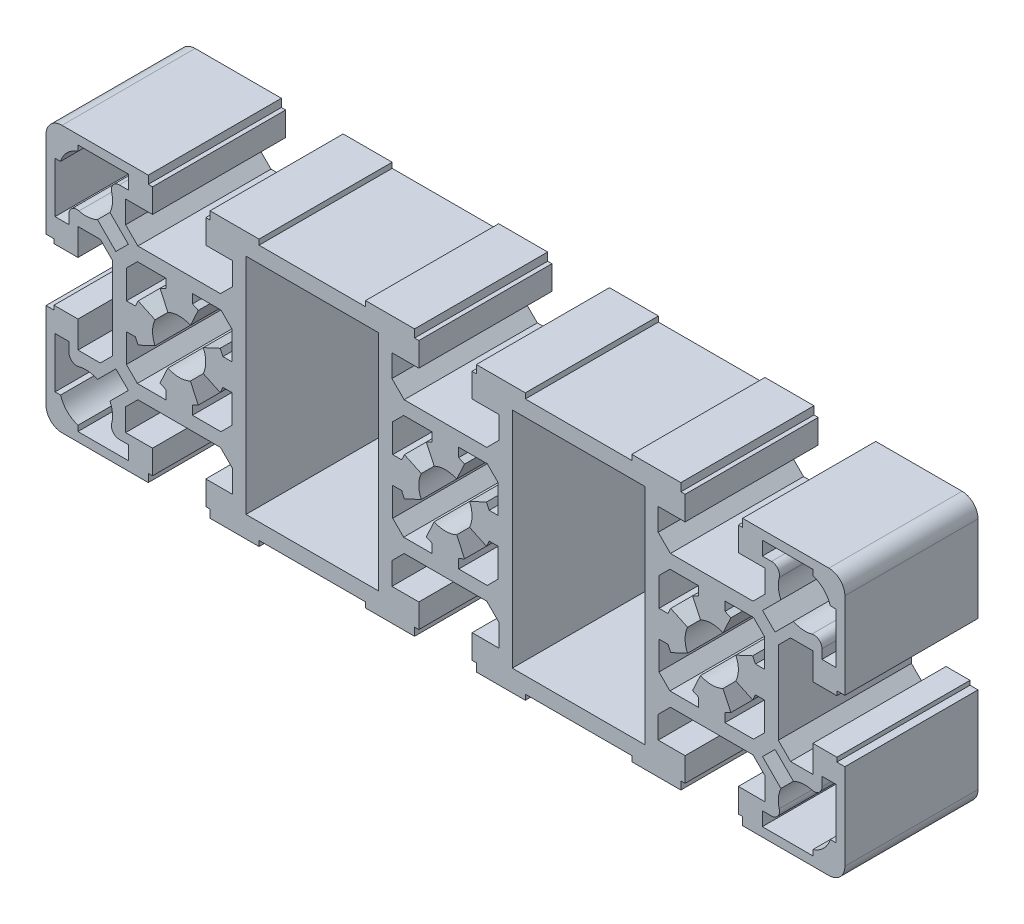
from build123d import *

# Parameters (mm, degrees)
SKETCH1_W           = 24.9
SKETCH1_H           = 41.99999997
BOSS_EXTRUDE1_DEPTH = 25


with BuildPart() as part:
    # Sketch1 → Boss-Extrude1 (new body)
    with BuildSketch(Plane.XY):
        with BuildLine():
            Line((73.500000293, 4.999999371), (73.500000293, 5.799999386))
            Line((73.500000293, 5.799999386), (75.000000293, 5.799999386))
            Line((75.000000293, 5.799999386), (75.000000293, 21.999999371))
            ThreePointArc((75.000000293, 21.999999371), (74.121320637, 24.121319714), (72.000000293, 24.999999371))
            Line((72.000000293, 24.999999371), (55.800000293, 24.999999371))
            Line((55.800000293, 24.999999371), (55.800000293, 23.499999371))
            Line((55.800000293, 23.499999371), (55.000000293, 23.499999371))
            Line((55.000000293, 23.499999371), (55.000000293, 18.999999317))
            Line((55.000000293, 18.999999317), (60.050000326, 18.999999317))
            Line((60.050000326, 18.999999317), (60.050000326, 14.799999386))
            Line((60.050000326, 14.799999386), (57.750000311, 12.499999371))
            Line((57.750000311, 12.499999371), (42.250000311, 12.499999371))
            Line((42.250000311, 12.499999371), (39.950000311, 14.799999371))
            Line((39.950000311, 14.799999371), (39.950000311, 18.999999317))
            Line((39.950000311, 18.999999317), (45.000000293, 18.999999317))
            Line((45.000000293, 18.999999317), (45.000000293, 23.499999371))
            Line((45.000000293, 23.499999371), (44.200000293, 23.499999371))
            Line((44.200000293, 23.499999371), (44.200000293, 24.999999371))
            Line((44.200000293, 24.999999371), (35.000000293, 24.999999371))
            Line((35.000000293, 24.999999371), (35.000000293, 23.999999401))
            Line((35.000000293, 23.999999401), (15.000000358, 23.999999401))
            Line((15.000000358, 23.999999401), (15.000000358, 24.999999371))
            Line((15.000000358, 24.999999371), (5.800000358, 24.999999371))
            Line((5.800000358, 24.999999371), (5.800000358, 23.499999371))
            Line((5.800000358, 23.499999371), (5.000000293, 23.499999371))
            Line((5.000000293, 23.499999371), (5.000000293, 18.999999317))
            Line((5.000000293, 18.999999317), (10.05000031, 18.999999317))
            Line((10.05000031, 18.999999317), (10.05000031, 14.799999402))
            Line((10.05000031, 14.799999402), (7.750000278, 12.499999371))
            Line((7.750000278, 12.499999371), (-7.749999689, 12.499999371))
            Line((-7.749999689, 12.499999371), (-10.04999969, 14.799999372))
            Line((-10.04999969, 14.799999372), (-10.04999969, 18.999999317))
            Line((-10.04999969, 18.999999317), (-4.999999707, 18.999999317))
            Line((-4.999999707, 18.999999317), (-4.999999707, 23.499999371))
            Line((-4.999999707, 23.499999371), (-5.799999707, 23.499999371))
            Line((-5.799999707, 23.499999371), (-5.799999707, 24.999999371))
            Line((-5.799999707, 24.999999371), (-14.999999707, 24.999999371))
            Line((-14.999999707, 24.999999371), (-14.999999707, 23.999999401))
            Line((-14.999999707, 23.999999401), (-34.999999707, 23.999999401))
            Line((-34.999999707, 23.999999401), (-34.999999707, 24.999999371))
            Line((-34.999999707, 24.999999371), (-44.199999707, 24.999999371))
            Line((-44.199999707, 24.999999371), (-44.199999707, 23.499999371))
            Line((-44.199999707, 23.499999371), (-44.999999707, 23.499999371))
            Line((-44.999999707, 23.499999371), (-44.999999707, 18.999999317))
            Line((-44.999999707, 18.999999317), (-39.949999674, 18.999999317))
            Line((-39.949999674, 18.999999317), (-39.949999674, 14.799999386))
            Line((-39.949999674, 14.799999386), (-42.249999689, 12.499999371))
            Line((-42.249999689, 12.499999371), (-57.749999689, 12.499999371))
            Line((-57.749999689, 12.499999371), (-60.049999674, 14.799999356))
            Line((-60.049999674, 14.799999356), (-60.049999674, 18.999999317))
            Line((-60.049999674, 18.999999317), (-54.999999707, 18.999999317))
            Line((-54.999999707, 18.999999317), (-54.999999707, 23.499999371))
            Line((-54.999999707, 23.499999371), (-55.799999707, 23.499999371))
            Line((-55.799999707, 23.499999371), (-55.799999707, 24.999999371))
            Line((-55.799999707, 24.999999371), (-71.999999707, 24.999999371))
            ThreePointArc((-71.999999707, 24.999999371), (-74.12132005, 24.121319714), (-74.999999707, 21.999999371))
            Line((-74.999999707, 21.999999371), (-74.999999707, 5.799999386))
            Line((-74.999999707, 5.799999386), (-73.499999707, 5.799999386))
            Line((-73.499999707, 5.799999386), (-73.499999707, 4.999999371))
            Line((-73.499999707, 4.999999371), (-68.9999997, 4.999999371))
            Line((-68.9999997, 4.999999371), (-68.9999997, 10.049999386))
            Line((-68.9999997, 10.049999386), (-64.799999674, 10.049999386))
            Line((-64.799999674, 10.049999386), (-62.499999674, 7.749999386))
            Line((-62.499999674, 7.749999386), (-62.499999674, -7.750000614))
            Line((-62.499999674, -7.750000614), (-64.799999689, -10.050000629))
            Line((-64.799999689, -10.050000629), (-68.9999997, -10.050000629))
            Line((-68.9999997, -10.050000629), (-68.9999997, -5.000000629))
            Line((-68.9999997, -5.000000629), (-73.499999707, -5.000000629))
            Line((-73.499999707, -5.000000629), (-73.499999707, -5.800000614))
            Line((-73.499999707, -5.800000614), (-74.999999707, -5.800000614))
            Line((-74.999999707, -5.800000614), (-74.999999707, -22.000000629))
            ThreePointArc((-74.999999707, -22.000000629), (-74.12132005, -24.121320973), (-71.999999707, -25.000000629))
            Line((-71.999999707, -25.000000629), (-55.799999707, -25.000000629))
            Line((-55.799999707, -25.000000629), (-55.799999707, -23.500000629))
            Line((-55.799999707, -23.500000629), (-54.999999707, -23.500000629))
            Line((-54.999999707, -23.500000629), (-54.999999707, -19.000000636))
            Line((-54.999999707, -19.000000636), (-60.049999674, -19.000000636))
            Line((-60.049999674, -19.000000636), (-60.049999674, -14.800000614))
            Line((-60.049999674, -14.800000614), (-57.749999674, -12.500000614))
            Line((-57.749999674, -12.500000614), (-42.249999674, -12.500000614))
            Line((-42.249999674, -12.500000614), (-39.949999674, -14.800000614))
            Line((-39.949999674, -14.800000614), (-39.949999674, -19.000000636))
            Line((-39.949999674, -19.000000636), (-44.999999707, -19.000000636))
            Line((-44.999999707, -19.000000636), (-44.999999707, -23.500000629))
            Line((-44.999999707, -23.500000629), (-44.199999707, -23.500000629))
            Line((-44.199999707, -23.500000629), (-44.199999707, -25.000000629))
            Line((-44.199999707, -25.000000629), (-34.999999707, -25.000000629))
            Line((-34.999999707, -25.000000629), (-34.999999707, -24.000000599))
            Line((-34.999999707, -24.000000599), (-14.999999707, -24.000000599))
            Line((-14.999999707, -24.000000599), (-14.999999707, -25.000000629))
            Line((-14.999999707, -25.000000629), (-5.799999707, -25.000000629))
            Line((-5.799999707, -25.000000629), (-5.799999707, -23.500000629))
            Line((-5.799999707, -23.500000629), (-4.999999707, -23.500000629))
            Line((-4.999999707, -23.500000629), (-4.999999707, -19.000000636))
            Line((-4.999999707, -19.000000636), (-10.04999969, -19.000000636))
            Line((-10.04999969, -19.000000636), (-10.04999969, -14.80000063))
            Line((-10.04999969, -14.80000063), (-7.749999674, -12.500000614))
            Line((-7.749999674, -12.500000614), (7.750000326, -12.500000614))
            Line((7.750000326, -12.500000614), (10.05000031, -14.800000598))
            Line((10.05000031, -14.800000598), (10.05000031, -19.000000636))
            Line((10.05000031, -19.000000636), (5.000000293, -19.000000636))
            Line((5.000000293, -19.000000636), (5.000000293, -23.500000629))
            Line((5.000000293, -23.500000629), (5.800000358, -23.500000629))
            Line((5.800000358, -23.500000629), (5.800000358, -25.000000629))
            Line((5.800000358, -25.000000629), (15.000000358, -25.000000629))
            Line((15.000000358, -25.000000629), (15.000000358, -24.000000599))
            Line((15.000000358, -24.000000599), (35.000000293, -24.000000599))
            Line((35.000000293, -24.000000599), (35.000000293, -25.000000629))
            Line((35.000000293, -25.000000629), (44.200000293, -25.000000629))
            Line((44.200000293, -25.000000629), (44.200000293, -23.500000629))
            Line((44.200000293, -23.500000629), (45.000000293, -23.500000629))
            Line((45.000000293, -23.500000629), (45.000000293, -19.000000636))
            Line((45.000000293, -19.000000636), (39.950000311, -19.000000636))
            Line((39.950000311, -19.000000636), (39.950000311, -14.800000629))
            Line((39.950000311, -14.800000629), (42.250000326, -12.500000614))
            Line((42.250000326, -12.500000614), (57.750000326, -12.500000614))
            Line((57.750000326, -12.500000614), (60.050000326, -14.800000614))
            Line((60.050000326, -14.800000614), (60.050000326, -19.000000636))
            Line((60.050000326, -19.000000636), (55.000000293, -19.000000636))
            Line((55.000000293, -19.000000636), (55.000000293, -23.500000629))
            Line((55.000000293, -23.500000629), (55.800000293, -23.500000629))
            Line((55.800000293, -23.500000629), (55.800000293, -25.000000629))
            Line((55.800000293, -25.000000629), (72.000000293, -25.000000629))
            ThreePointArc((72.000000293, -25.000000629), (74.121320637, -24.121320973), (75.000000293, -22.000000629))
            Line((75.000000293, -22.000000629), (75.000000293, -5.800000614))
            Line((75.000000293, -5.800000614), (73.500000293, -5.800000614))
            Line((73.500000293, -5.800000614), (73.500000293, -5.000000629))
            Line((73.500000293, -5.000000629), (69.000000258, -5.000000629))
            Line((69.000000258, -5.000000629), (69.000000258, -10.050000629))
            Line((69.000000258, -10.050000629), (64.800000311, -10.050000629))
            Line((64.800000311, -10.050000629), (62.500000427, -7.750000745))
            Line((62.500000427, -7.750000745), (62.500000427, 7.749999487))
            Line((62.500000427, 7.749999487), (64.800000326, 10.049999386))
            Line((64.800000326, 10.049999386), (69.000000258, 10.049999386))
            Line((69.000000258, 10.049999386), (69.000000258, 4.999999371))
            Line((69.000000258, 4.999999371), (73.500000293, 4.999999371))
        make_face()
        with BuildLine():
            Line((72.269696311, 18.999999317), (73.300000192, 18.999999317))
            Line((73.300000192, 18.999999317), (73.300000192, 9.499999364))
            Line((73.300000192, 9.499999364), (70.70000022, 9.499999364))
            Line((70.70000022, 9.499999364), (70.70000022, 11.226244464))
            ThreePointArc((70.70000022, 11.226244464), (70.111465657, 12.417559181), (68.807692546, 12.674034051))
            ThreePointArc((68.807692546, 12.674034051), (67.044077418, 12.520829299), (65.337613319, 12.991775464))
            Line((65.337613319, 12.991775464), (61.884693162, 9.538855411))
            Line((61.884693162, 9.538855411), (59.538856304, 11.884692341))
            Line((59.538856304, 11.884692341), (62.991776426, 15.337612357))
            ThreePointArc((62.991776426, 15.337612357), (62.520830259, 17.04407647), (62.67403502, 18.80769161))
            ThreePointArc((62.67403502, 18.80769161), (62.417560154, 20.111464726), (61.226245435, 20.699999291))
            Line((61.226245435, 20.699999291), (59.500000371, 20.699999291))
            Line((59.500000371, 20.699999291), (59.500000371, 23.299999301))
            Line((59.500000371, 23.299999301), (69.000000258, 23.299999301))
            Line((69.000000258, 23.299999301), (69.000000258, 22.269695356))
            ThreePointArc((69.000000258, 22.269695356), (71.035534197, 21.03553325), (72.269696311, 18.999999317))
        make_face(mode=Mode.SUBTRACT)
        with BuildLine():
            Line((62.991776382, -15.337613665), (59.538856312, -11.884693596))
            Line((59.538856312, -11.884693596), (61.884693206, -9.538856703))
            Line((61.884693206, -9.538856703), (65.337613275, -12.991776772))
            ThreePointArc((65.337613275, -12.991776772), (67.044077392, -12.520830605), (68.807692536, -12.674035369))
            ThreePointArc((68.807692536, -12.674035369), (70.111465653, -12.417560504), (70.70000022, -11.226245784))
            Line((70.70000022, -11.226245784), (70.70000022, -9.500000636))
            Line((70.70000022, -9.500000636), (73.300000192, -9.500000636))
            Line((73.300000192, -9.500000636), (73.300000192, -19.000000636))
            Line((73.300000192, -19.000000636), (72.269696264, -19.000000636))
            ThreePointArc((72.269696264, -19.000000636), (71.035534165, -21.035534546), (69.000000258, -22.26969665))
            Line((69.000000258, -22.26969665), (69.000000258, -23.300000698))
            Line((69.000000258, -23.300000698), (59.500000371, -23.300000698))
            Line((59.500000371, -23.300000698), (59.500000371, -20.700000607))
            Line((59.500000371, -20.700000607), (61.226245393, -20.700000607))
            ThreePointArc((61.226245393, -20.700000607), (62.417560113, -20.111466041), (62.674034977, -18.807692924))
            ThreePointArc((62.674034977, -18.807692924), (62.520830215, -17.044077781), (62.991776382, -15.337613665))
        make_face(mode=Mode.SUBTRACT)
        with BuildLine():
            Line((-62.991775824, 15.337612346), (-59.538855738, 11.884692365))
            Line((-59.538855738, 11.884692365), (-61.884692596, 9.538855436))
            Line((-61.884692596, 9.538855436), (-65.337612718, 12.991775453))
            ThreePointArc((-65.337612718, 12.991775453), (-67.044076833, 12.520829286), (-68.807691976, 12.674034049))
            ThreePointArc((-68.807691976, 12.674034049), (-70.111465093, 12.417559184), (-70.699999659, 11.226244464))
            Line((-70.699999659, 11.226244464), (-70.699999659, 9.499999364))
            Line((-70.699999659, 9.499999364), (-73.299999743, 9.499999364))
            Line((-73.299999743, 9.499999364), (-73.299999743, 18.999999317))
            Line((-73.299999743, 18.999999317), (-72.269695706, 18.999999317))
            ThreePointArc((-72.269695706, 18.999999317), (-71.035533607, 21.035533227), (-68.9999997, 22.269695331))
            Line((-68.9999997, 22.269695331), (-68.9999997, 23.299999301))
            Line((-68.9999997, 23.299999301), (-59.4999997, 23.299999301))
            Line((-59.4999997, 23.299999301), (-59.4999997, 20.699999291))
            Line((-59.4999997, 20.699999291), (-61.226244836, 20.699999291))
            ThreePointArc((-61.226244836, 20.699999291), (-62.417559556, 20.111464725), (-62.674034421, 18.807691607))
            ThreePointArc((-62.674034421, 18.807691607), (-62.520829657, 17.044076463), (-62.991775824, 15.337612346))
        make_face(mode=Mode.SUBTRACT)
        with BuildLine():
            Line((-61.226244744, -20.700000607), (-59.4999997, -20.700000607))
            Line((-59.4999997, -20.700000607), (-59.4999997, -23.300000698))
            Line((-59.4999997, -23.300000698), (-68.9999997, -23.300000698))
            Line((-68.9999997, -23.300000698), (-68.9999997, -22.269696698))
            ThreePointArc((-68.9999997, -22.269696698), (-71.035533637, -21.035534576), (-72.269695754, -19.000000636))
            Line((-72.269695754, -19.000000636), (-73.299999743, -19.000000636))
            Line((-73.299999743, -19.000000636), (-73.299999743, -9.500000636))
            Line((-73.299999743, -9.500000636), (-70.699999659, -9.500000636))
            Line((-70.699999659, -9.500000636), (-70.699999659, -11.226245692))
            ThreePointArc((-70.699999659, -11.226245692), (-70.111465093, -12.417560412), (-68.807691975, -12.674035277))
            ThreePointArc((-68.807691975, -12.674035277), (-67.044076806, -12.520830511), (-65.337612664, -12.991776685))
            Line((-65.337612664, -12.991776685), (-61.884692647, -9.538856563))
            Line((-61.884692647, -9.538856563), (-59.538855684, -11.884693455))
            Line((-59.538855684, -11.884693455), (-62.991775737, -15.337613612))
            ThreePointArc((-62.991775737, -15.337613612), (-62.520829563, -17.044077754), (-62.674034329, -18.807692923))
            ThreePointArc((-62.674034329, -18.807692923), (-62.417559465, -20.111466041), (-61.226244744, -20.700000607))
        make_face(mode=Mode.SUBTRACT)
        with BuildLine():
            Line((-3.592255382, 7.703615177), (-2.113091613, 4.531538793))
            ThreePointArc((-2.113091613, 4.531538793), (-5.12e-07, 5), (2.113090685, 4.531539226))
            Line((2.113090685, 4.531539226), (3.592253985, 7.703616301))
            Line((3.592253985, 7.703616301), (2.500000278, 8.212942386))
            Line((2.500000278, 8.212942386), (2.500000278, 9.899999386))
            Line((2.500000278, 9.899999386), (7.846595278, 9.899999386))
            Line((7.846595278, 9.899999386), (9.900000262, 7.84659437))
            Line((9.900000262, 7.84659437), (9.900000262, 2.499999386))
            Line((9.900000262, 2.499999386), (8.212943262, 2.499999386))
            Line((8.212943262, 2.499999386), (7.703615719, 3.592255635))
            Line((7.703615719, 3.592255635), (4.531538793, 2.113091613))
            ThreePointArc((4.531538793, 2.113091613), (5, -2.7e-08), (4.531538771, -2.113091661))
            Line((4.531538771, -2.113091661), (7.70361614, -3.592255931))
            Line((7.70361614, -3.592255931), (8.212943262, -2.500000614))
            Line((8.212943262, -2.500000614), (9.900000262, -2.500000614))
            Line((9.900000262, -2.500000614), (9.900000262, -7.846595598))
            Line((9.900000262, -7.846595598), (7.846595278, -9.900000614))
            Line((7.846595278, -9.900000614), (2.500000278, -9.900000614))
            Line((2.500000278, -9.900000614), (2.500000278, -8.212943614))
            Line((2.500000278, -8.212943614), (3.592255929, -7.70361635))
            Line((3.592255929, -7.70361635), (2.113091613, -4.531538793))
            ThreePointArc((2.113091613, -4.531538793), (5.12e-07, -5), (-2.113090685, -4.531539226))
            Line((-2.113090685, -4.531539226), (-3.592254051, -7.703616443))
            Line((-3.592254051, -7.703616443), (-2.499998932, -8.212943186))
            Line((-2.499998932, -8.212943186), (-2.499998932, -9.900000614))
            Line((-2.499998932, -9.900000614), (-7.846594674, -9.900000614))
            Line((-7.846594674, -9.900000614), (-9.899999674, -7.846595614))
            Line((-9.899999674, -7.846595614), (-9.899999674, -2.500000614))
            Line((-9.899999674, -2.500000614), (-8.212942674, -2.500000614))
            Line((-8.212942674, -2.500000614), (-7.703615707, -3.592255629))
            Line((-7.703615707, -3.592255629), (-4.531538793, -2.113091613))
            ThreePointArc((-4.531538793, -2.113091613), (-5, 2.7e-08), (-4.531538771, 2.113091661))
            Line((-4.531538771, 2.113091661), (-7.703615187, 3.592255486))
            Line((-7.703615187, 3.592255486), (-8.212942674, 2.499999386))
            Line((-8.212942674, 2.499999386), (-9.899999674, 2.499999386))
            Line((-9.899999674, 2.499999386), (-9.899999674, 7.846594386))
            Line((-9.899999674, 7.846594386), (-7.846594674, 9.899999386))
            Line((-7.846594674, 9.899999386), (-2.499998932, 9.899999386))
            Line((-2.499998932, 9.899999386), (-2.499998932, 8.212942814))
            Line((-2.499998932, 8.212942814), (-3.592255382, 7.703615177))
        make_face(mode=Mode.SUBTRACT)
        with BuildLine():
            Line((52.500000278, 8.212942386), (52.500000278, 9.899999386))
            Line((52.500000278, 9.899999386), (57.846595278, 9.899999386))
            Line((57.846595278, 9.899999386), (59.900000261, 7.846594369))
            Line((59.900000261, 7.846594369), (59.900000261, 2.499999386))
            Line((59.900000261, 2.499999386), (58.212943261, 2.499999386))
            Line((58.212943261, 2.499999386), (57.703615469, 3.592256084))
            Line((57.703615469, 3.592256084), (54.531538639, 2.113091992))
            ThreePointArc((54.531538639, 2.113091992), (54.999999908, 2.57e-07), (54.531538649, -2.113091481))
            Line((54.531538649, -2.113091481), (57.70361615, -3.592255866))
            Line((57.70361615, -3.592255866), (58.212943261, -2.500000614))
            Line((58.212943261, -2.500000614), (59.900000261, -2.500000614))
            Line((59.900000261, -2.500000614), (59.900000261, -7.846595597))
            Line((59.900000261, -7.846595597), (57.846595278, -9.900000614))
            Line((57.846595278, -9.900000614), (52.500000278, -9.900000614))
            Line((52.500000278, -9.900000614), (52.500000278, -8.212943614))
            Line((52.500000278, -8.212943614), (53.592255245, -7.703616799))
            Line((53.592255245, -7.703616799), (52.113091079, -4.531538755))
            ThreePointArc((52.113091079, -4.531538755), (50.000000247, -4.999999756), (47.886909352, -4.531539042))
            Line((47.886909352, -4.531539042), (46.407746076, -7.7036163))
            Line((46.407746076, -7.7036163), (47.50000121, -8.212943013))
            Line((47.50000121, -8.212943013), (47.50000121, -9.900000614))
            Line((47.50000121, -9.900000614), (42.153405309, -9.900000614))
            Line((42.153405309, -9.900000614), (40.100000309, -7.846595614))
            Line((40.100000309, -7.846595614), (40.100000309, -2.500000614))
            Line((40.100000309, -2.500000614), (41.787057309, -2.500000614))
            Line((41.787057309, -2.500000614), (42.296384309, -3.592255614))
            Line((42.296384309, -3.592255614), (45.468461178, -2.113091503))
            ThreePointArc((45.468461178, -2.113091503), (44.999999908, 2.32e-07), (45.468461167, 2.113091969))
            Line((45.468461167, 2.113091969), (42.296384943, 3.59225576))
            Line((42.296384943, 3.59225576), (41.787057309, 2.499999386))
            Line((41.787057309, 2.499999386), (40.100000309, 2.499999386))
            Line((40.100000309, 2.499999386), (40.100000309, 7.846594386))
            Line((40.100000309, 7.846594386), (42.153405309, 9.899999386))
            Line((42.153405309, 9.899999386), (47.50000121, 9.899999386))
            Line((47.50000121, 9.899999386), (47.50000121, 8.212942987))
            Line((47.50000121, 8.212942987), (46.407745297, 7.703615731))
            Line((46.407745297, 7.703615731), (47.886908738, 4.531539244))
            ThreePointArc((47.886908738, 4.531539244), (49.999999569, 5.000000244), (52.113090464, 4.531539531))
            Line((52.113090464, 4.531539531), (53.592253612, 7.703616513))
            Line((53.592253612, 7.703616513), (52.500000278, 8.212942386))
        make_face(mode=Mode.SUBTRACT)
        with BuildLine():
            Line((-40.099999722, 2.499999386), (-41.787056722, 2.499999386))
            Line((-41.787056722, 2.499999386), (-42.296384514, 3.592256084))
            Line((-42.296384514, 3.592256084), (-45.468461344, 2.113091992))
            ThreePointArc((-45.468461344, 2.113091992), (-45.000000074, 2.71e-07), (-45.468461321, -2.113091455))
            Line((-45.468461321, -2.113091455), (-42.296383806, -3.592255826))
            Line((-42.296383806, -3.592255826), (-41.787056722, -2.500000614))
            Line((-41.787056722, -2.500000614), (-40.099999722, -2.500000614))
            Line((-40.099999722, -2.500000614), (-40.099999722, -7.846595614))
            Line((-40.099999722, -7.846595614), (-42.153404722, -9.900000614))
            Line((-42.153404722, -9.900000614), (-47.499999722, -9.900000614))
            Line((-47.499999722, -9.900000614), (-47.499999722, -8.212943614))
            Line((-47.499999722, -8.212943614), (-46.407744702, -7.703616767))
            Line((-46.407744702, -7.703616767), (-47.886908879, -4.531538744))
            ThreePointArc((-47.886908879, -4.531538744), (-49.999999702, -4.999999756), (-52.113090594, -4.531539059))
            Line((-52.113090594, -4.531539059), (-53.592253845, -7.703616329))
            Line((-53.592253845, -7.703616329), (-52.499998707, -8.212943033))
            Line((-52.499998707, -8.212943033), (-52.499998707, -9.900000614))
            Line((-52.499998707, -9.900000614), (-57.846594674, -9.900000614))
            Line((-57.846594674, -9.900000614), (-59.899999674, -7.846595614))
            Line((-59.899999674, -7.846595614), (-59.899999674, -2.500000614))
            Line((-59.899999674, -2.500000614), (-58.212942674, -2.500000614))
            Line((-58.212942674, -2.500000614), (-57.703615674, -3.592255614))
            Line((-57.703615674, -3.592255614), (-54.531538805, -2.113091503))
            ThreePointArc((-54.531538805, -2.113091503), (-55.000000074, 2.18e-07), (-54.531538827, 2.113091944))
            Line((-54.531538827, 2.113091944), (-57.703615066, 3.59225572))
            Line((-57.703615066, 3.59225572), (-58.212942674, 2.499999386))
            Line((-58.212942674, 2.499999386), (-59.899999674, 2.499999386))
            Line((-59.899999674, 2.499999386), (-59.899999674, 7.846594386))
            Line((-59.899999674, 7.846594386), (-57.846594674, 9.899999386))
            Line((-57.846594674, 9.899999386), (-52.499998707, 9.899999386))
            Line((-52.499998707, 9.899999386), (-52.499998707, 8.212942967))
            Line((-52.499998707, 8.212942967), (-53.592254705, 7.703615664))
            Line((-53.592254705, 7.703615664), (-52.11309127, 4.531539232))
            ThreePointArc((-52.11309127, 4.531539232), (-50.000000447, 5.000000244), (-47.886909554, 4.531539547))
            Line((-47.886909554, 4.531539547), (-46.407746431, 7.703616543))
            Line((-46.407746431, 7.703616543), (-47.499999722, 8.212942386))
            Line((-47.499999722, 8.212942386), (-47.499999722, 9.899999386))
            Line((-47.499999722, 9.899999386), (-42.153404722, 9.899999386))
            Line((-42.153404722, 9.899999386), (-40.099999722, 7.846594386))
            Line((-40.099999722, 7.846594386), (-40.099999722, 2.499999386))
        make_face(mode=Mode.SUBTRACT)
        with Locations((-24.999999674, -6.29e-07)):
            Rectangle(SKETCH1_W, SKETCH1_H, mode=Mode.SUBTRACT)
        with Locations((25.000000261, -6.29e-07)):
            Rectangle(SKETCH1_W, SKETCH1_H, mode=Mode.SUBTRACT)
    extrude(amount=-BOSS_EXTRUDE1_DEPTH)


solid = part.part
